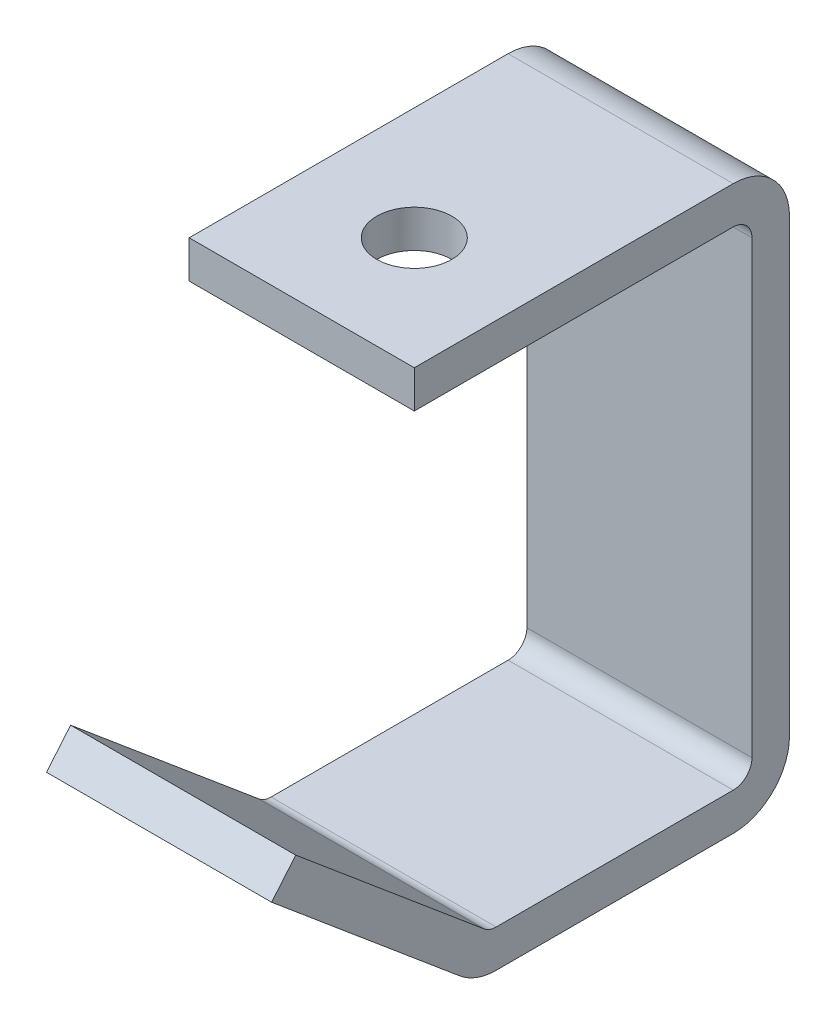
from build123d import *

# Parameters (mm, degrees)
BASE_EXTRUDE_THIN_DEPTH = 19.05
CUT_EXTRUDE1_REACH      = 97.25
SKETCH2_R               = 6.35


with BuildPart() as part:
    # Sketch1 → Base-Extrude-Thin (new body, symmetric)
    with BuildSketch(Plane(origin=(0, 0, 0), x_dir=(0, 0, -1), z_dir=(1, 0, 0))):
        with BuildLine():
            Line((-77.216478592, 27.494340102), (-45.335245167, 0.742808893))
            ThreePointArc((-45.335245167, 0.742808893), (-44.380308461, 0.191475929), (-43.294394506, 0))
            Line((-43.294394506, 0), (-3.175, 0))
            ThreePointArc((-3.175, 0), (-0.92993597, 0.92993597), (0, 3.175))
            Line((0, 3.175), (0, 79.375))
            ThreePointArc((0, 79.375), (-0.92993597, 81.62006403), (-3.175, 82.55))
            Line((-3.175, 82.55), (-57.15, 82.55))
            Line((-57.15, 82.55), (-57.15, 88.9))
            Line((-57.15, 88.9), (-3.175, 88.9))
            ThreePointArc((-3.175, 88.9), (3.560192091, 86.110192091), (6.35, 79.375))
            Line((6.35, 79.375), (6.35, 3.175))
            ThreePointArc((6.35, 3.175), (3.560192091, -3.560192091), (-3.175, -6.35))
            Line((-3.175, -6.35), (-43.294394506, -6.35))
            ThreePointArc((-43.294394506, -6.35), (-46.552136371, -5.775572213), (-49.416946488, -4.121573321))
            Line((-49.416946488, -4.121573321), (-81.298179914, 22.629957888))
            Line((-81.298179914, 22.629957888), (-77.216478592, 27.494340102))
        make_face()
    extrude(amount=BASE_EXTRUDE_THIN_DEPTH, both=True)

    # Sketch2 → Cut-Extrude1 (cut, up to next)
    with BuildSketch(Plane(origin=(0, 88.9, 0), x_dir=(-1, 0, 0), z_dir=(0, 1, 0)), mode=Mode.PRIVATE) as cut_extrude1_sk1:
        with Locations((0, 38.1)):
            Circle(SKETCH2_R)
    cut_extrude1_tool1 = extrude(cut_extrude1_sk1.sketch, amount=-CUT_EXTRUDE1_REACH, mode=Mode.PRIVATE) & part.part
    add(cut_extrude1_tool1.solids().sort_by_distance((0, 88.9, 38.1))[0], mode=Mode.SUBTRACT)


solid = part.part
